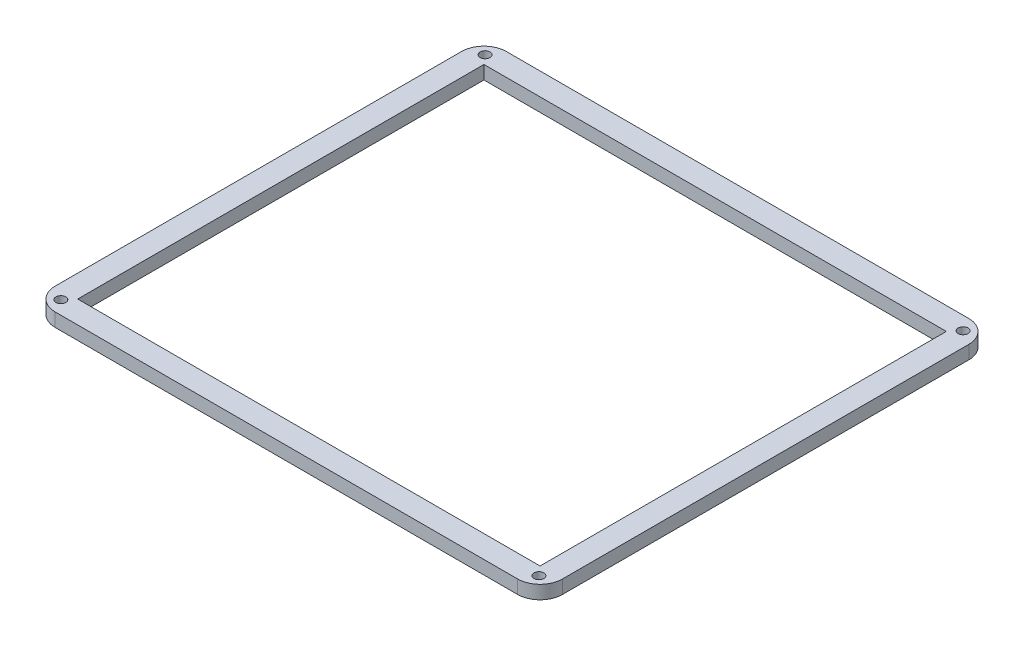
from build123d import *

# Parameters (mm, degrees)
SKETCH1_R           = 1.1
SKETCH1_W           = 103
SKETCH1_H           = 90.5
BOSS_EXTRUDE1_DEPTH = 3


with BuildPart() as part:
    # Sketch1 → Boss-Extrude1 (new body)
    with BuildSketch(Plane(origin=(0, 0, 0), x_dir=(1, 0, 0), z_dir=(0, 1, 0))):
        with BuildLine():
            Line((-51.5, -50.25), (51.5, -50.25))
            ThreePointArc((51.5, -50.25), (55.035533906, -48.785533906), (56.5, -45.25))
            Line((56.5, -45.25), (56.5, 45.25))
            ThreePointArc((56.5, 45.25), (55.035533906, 48.785533906), (51.5, 50.25))
            Line((51.5, 50.25), (-51.5, 50.25))
            ThreePointArc((-51.5, 50.25), (-55.035533906, 48.785533906), (-56.5, 45.25))
            Line((-56.5, 45.25), (-56.5, -45.25))
            ThreePointArc((-56.5, -45.25), (-55.035533906, -48.785533906), (-51.5, -50.25))
        make_face()
        with Locations((-53.25, 47.25)):
            Circle(SKETCH1_R, mode=Mode.SUBTRACT)
        with Locations((53.25, 47.25)):
            Circle(SKETCH1_R, mode=Mode.SUBTRACT)
        with Locations((53.25, -47.25)):
            Circle(SKETCH1_R, mode=Mode.SUBTRACT)
        with Locations((-53.25, -47.25)):
            Circle(SKETCH1_R, mode=Mode.SUBTRACT)
        Rectangle(SKETCH1_W, SKETCH1_H, mode=Mode.SUBTRACT)
    extrude(amount=BOSS_EXTRUDE1_DEPTH)


solid = part.part
